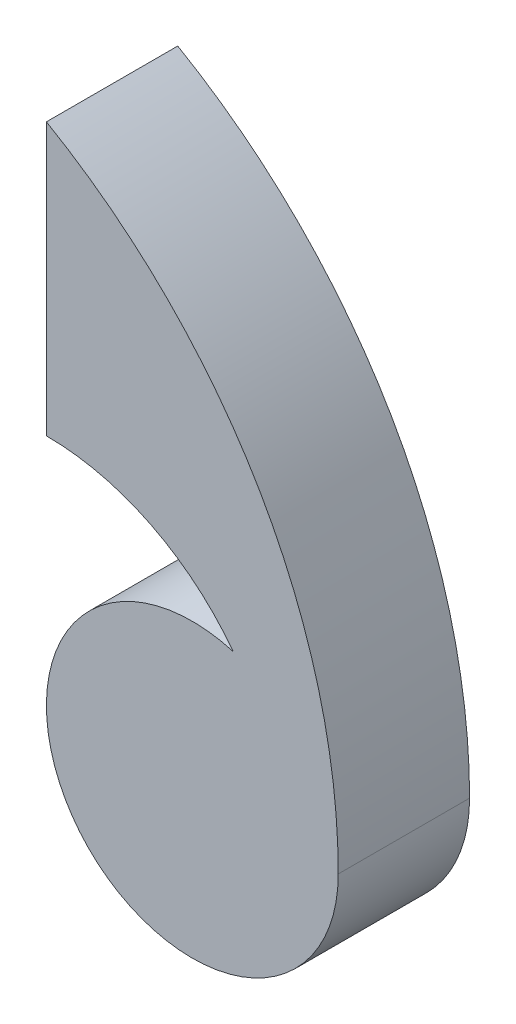
from build123d import *

# Parameters (mm, degrees)
SKETCH_1_R      = 20
EXTRUDE_1_DEPTH = 18
EXTRUDE_2_DEPTH = 18


with BuildPart() as part:
    # 草图1 → 凸台-拉伸1 (new body)
    with BuildSketch(Plane.XY):
        Circle(SKETCH_1_R)
    extrude(amount=EXTRUDE_1_DEPTH)

    # 草图2 → 凸台-拉伸2 (add)
    with BuildSketch(Plane.XY.offset(18)):
        with BuildLine():
            Line((-20, 69.282032303), (-20, 32))
            ThreePointArc((-20, 32), (2.627416998, 22.627416998), (12, 0))
            Line((12, 0), (20, 0))
            ThreePointArc((20, 0), (9.282032303, 40), (-20, 69.282032303))
        make_face()
    extrude(amount=-EXTRUDE_2_DEPTH)


solid = part.part
